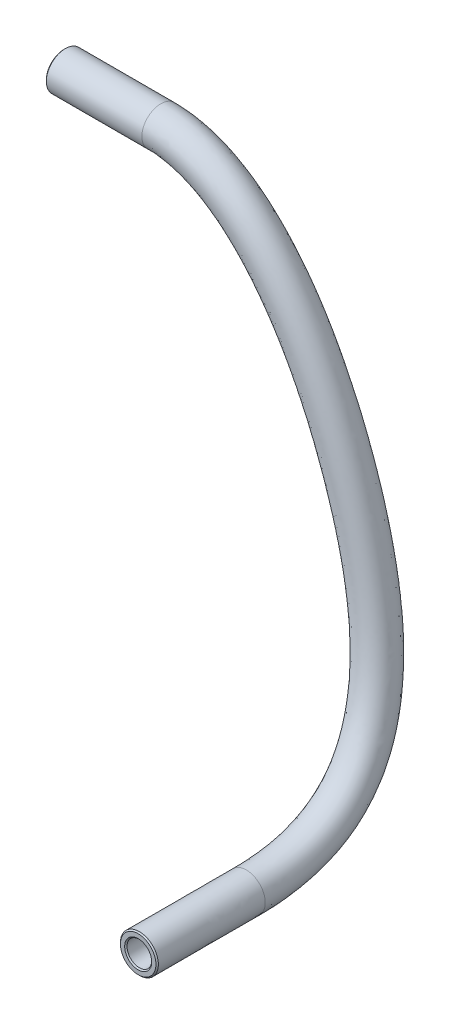
from build123d import *

# Parameters (mm, degrees)
SKETCH1_R     = 2
SKETCH1_R_2   = 1.3
CHAMFER1_SIZE = 0.127


with BuildPart() as part:
    # Sweep1: sweep along a curve in space
    with BuildLine() as sweep1_path:
        Line((96.825, -106.482256564, 33.525), (107.025, -106.482256564, 33.525))
        add(Edge.make_bspline(
            [(107.025, -106.482256564, 33.525), (116.342877351, -106.482256564, 33.525), (130.047278807, -131.130747458, 32.098386942), (132.201525762, -155.779238351, 34.068537234), (132.201525762, -155.779238351, 49.6875)],
            knots=[0, 0, 0, 0, 0.484757218, 1, 1, 1, 1], degree=3))
        Line((132.201525762, -155.779238351, 49.6875), (132.201525762, -155.779238351, 61.0875))
    # Sketch1 → Sweep1 (sweep)
    with BuildSketch(Plane(origin=(104.925, 0, 0), x_dir=(0, 0, -1), z_dir=(1, 0, 0))):
        with Locations((-33.525, -106.482256564)):
            Circle(SKETCH1_R)
        with Locations((-33.525, -106.482256564)):
            Circle(SKETCH1_R_2, mode=Mode.SUBTRACT)
    sweep(path=sweep1_path.line)

    # Chamfer1
    chamfer1_edges = [part.edges().sort_by_distance(p)[0] for p in [
        (96.825, -106.482256564, 34.825),
        (132.009979622, -154.493427294, 61.0875),
        (96.825, -106.482256564, 35.525),
        (131.906839393, -153.801067493, 61.0875),
    ]]
    chamfer(chamfer1_edges, length=CHAMFER1_SIZE)


solid = part.part
